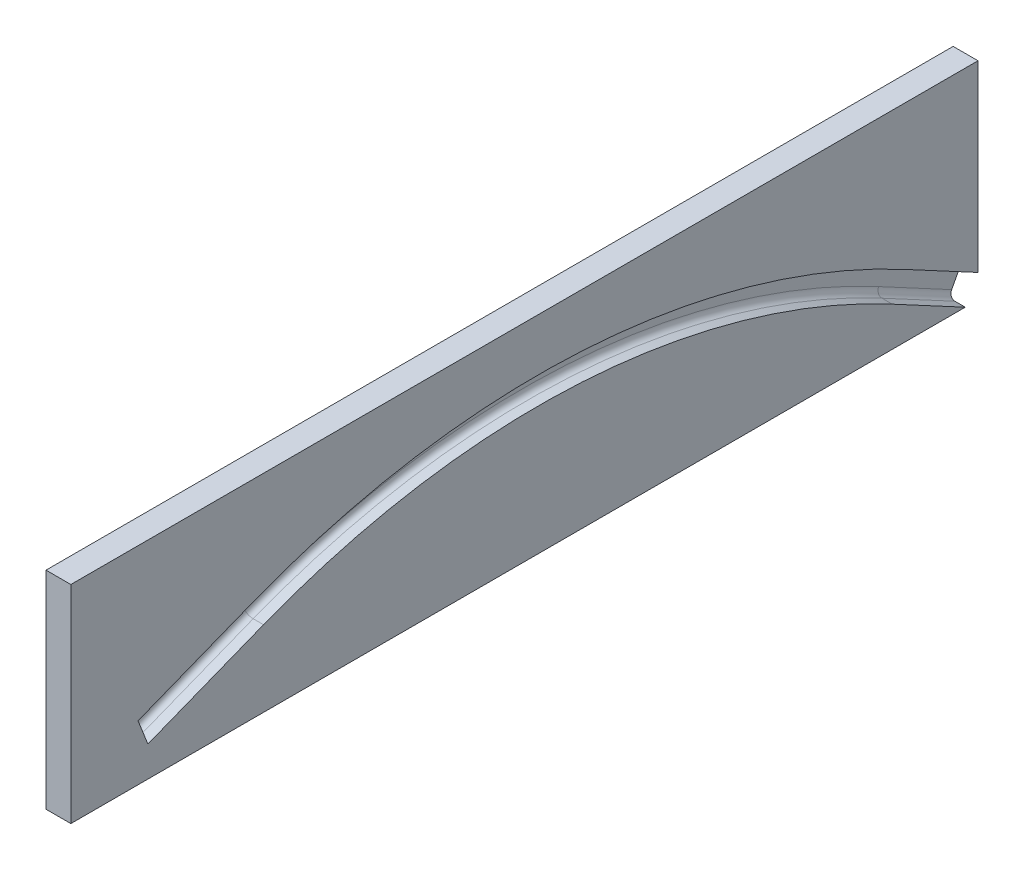
from build123d import *

# Parameters (mm, degrees)
RESSALTO_EXTRUS_O1_DEPTH = 2
RESSALTO_EXTRUS_O2_DEPTH = 4
FILETE1_R                = 1.5


with BuildPart() as part:
    # Esboço2 → Ressalto-extrusão1 (new body)
    with BuildSketch(Plane(origin=(3.965165603, 1.072526679, 0.020251395), x_dir=(0, 0, 1), z_dir=(-1, 0, 0))):
        Polygon((-106.20773335, 198.936503302), (-106.20773335, 154.66514884), (-103.13647623, 148.936503302), (112.820148392, 148.936503302), (112.820148392, 198.936503302), align=None)
    extrude(amount=RESSALTO_EXTRUS_O1_DEPTH)

    # Esboço2<3> → Ressalto-extrusão2 (add)
    with BuildSketch(Plane(origin=(3.965165603, 1.072526679, 0.020251395), x_dir=(0, 0, 1), z_dir=(-1, 0, 0))):
        with BuildLine():
            Line((-85.509874573, 158.386525208), (-103.13647623, 148.936503302))
            Line((-103.13647623, 148.936503302), (112.820148392, 148.936503302))
            Line((112.820148392, 148.936503302), (112.820148392, 198.936503302))
            Line((112.820148392, 198.936503302), (-106.20773335, 198.936503302))
            Line((-106.20773335, 198.936503302), (-106.20773335, 154.66514884))
            Line((-106.20773335, 154.66514884), (-88.581131693, 164.115170747))
            ThreePointArc((-88.581131693, 164.115170747), (-10.962219944, 186.037810353), (68.682901646, 173.31176637))
            Line((68.682901646, 173.31176637), (96.594808979, 162.315156482))
            Line((96.594808979, 162.315156482), (94.21221017, 156.26757656))
            Line((94.21221017, 156.26757656), (66.300302837, 167.264186448))
            ThreePointArc((66.300302837, 167.264186448), (-10.582756701, 179.548896141), (-85.509874573, 158.386525208))
        make_face()
    extrude(amount=-RESSALTO_EXTRUS_O2_DEPTH)

    # Filete1
    filete1_edges = [part.edges().sort_by_distance(p)[0] for p in [
        (3.965165603, 154.734040934, -94.302924007),
        (3.965165603, 160.462686473, -97.374181126),
        (3.965165603, 180.62142282, -10.562505306),
        (3.965165603, 162.838408183, 80.276507899),
        (3.965165603, 168.885988105, 82.659106708),
        (3.965165603, 187.110337032, -10.941968548),
    ]]
    fillet(filete1_edges, radius=FILETE1_R)


solid = part.part
